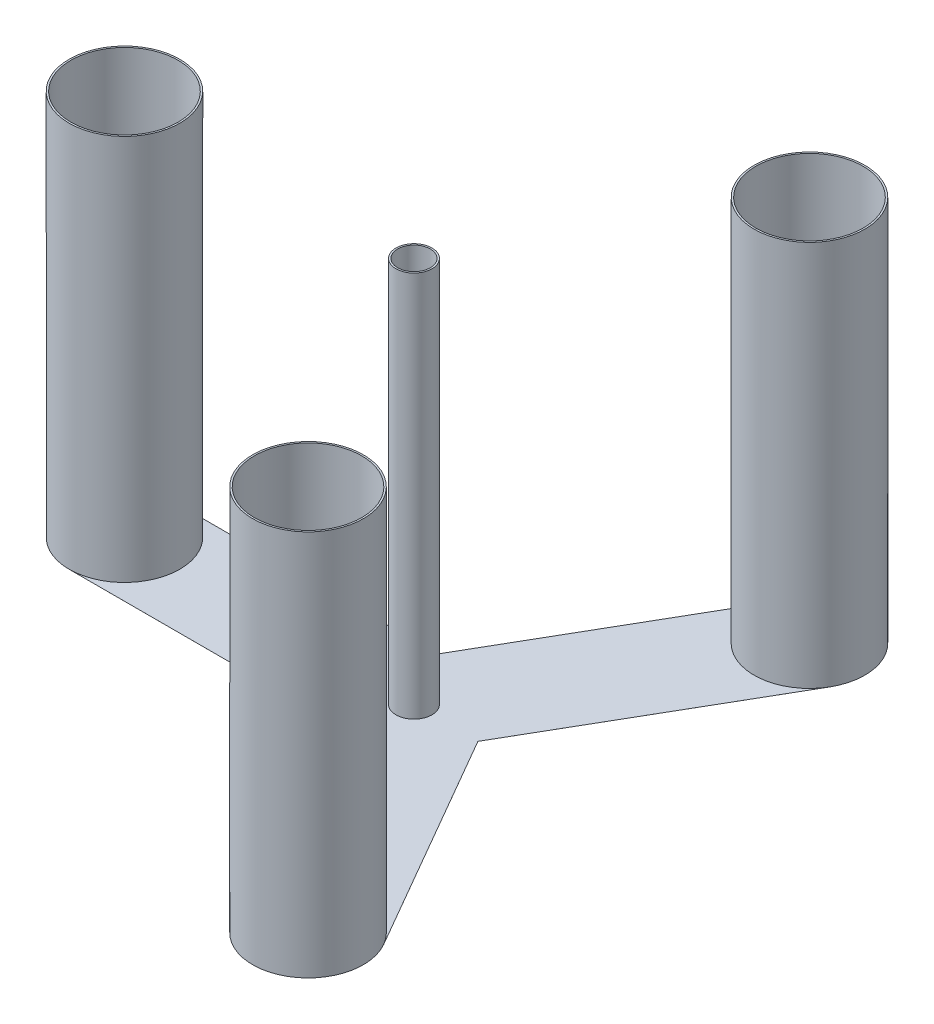
from build123d import *

# Parameters (mm, degrees)
BOSS_EXTRUDE1_DEPTH = 0.01
SKETCH2_R           = 64.5
SKETCH2_R_2         = 62.5
SKETCH2_R_3         = 21
SKETCH2_R_4         = 19
BOSS_EXTRUDE2_DEPTH = 450


with BuildPart() as part:
    # Sketch1 → Boss-Extrude1 (new body)
    with BuildSketch(Plane(origin=(0, 0, 0), x_dir=(1, 0, 0), z_dir=(0, 1, 0))):
        with BuildLine():
            Line((-37.239092363, 64.5), (-337.239092363, 64.5))
            ThreePointArc((-337.239092363, 64.5), (-401.739092363, 0), (-337.239092363, -64.5))
            Line((-337.239092363, -64.5), (-37.239092363, -64.5))
            Line((-37.239092363, -64.5), (112.760907637, -324.307621135))
            ThreePointArc((112.760907637, -324.307621135), (200.869546181, -347.916259679), (224.478184725, -259.807621135))
            Line((224.478184725, -259.807621135), (74.478184725, 0))
            Line((74.478184725, 0), (224.478184725, 259.807621135))
            ThreePointArc((224.478184725, 259.807621135), (200.869546181, 347.916259679), (112.760907637, 324.307621135))
            Line((112.760907637, 324.307621135), (-37.239092363, 64.5))
        make_face()
    extrude(amount=BOSS_EXTRUDE1_DEPTH)

    # Sketch2 → Boss-Extrude2 (add)
    with BuildSketch(Plane(origin=(0, 0.01, 0), x_dir=(1, 0, 0), z_dir=(0, 1, 0))):
        with Locations((168.619546181, 292.057621135)):
            Circle(SKETCH2_R)
        with Locations((168.619546181, 292.057621135)):
            Circle(SKETCH2_R_2, mode=Mode.SUBTRACT)
        with Locations((-337.239092363, 0)):
            Circle(SKETCH2_R)
        with Locations((-337.239092363, 0)):
            Circle(SKETCH2_R_2, mode=Mode.SUBTRACT)
        with Locations((168.619546181, -292.057621135)):
            Circle(SKETCH2_R)
        with Locations((168.619546181, -292.057621135)):
            Circle(SKETCH2_R_2, mode=Mode.SUBTRACT)
        Circle(SKETCH2_R_3)
        Circle(SKETCH2_R_4, mode=Mode.SUBTRACT)
    extrude(amount=BOSS_EXTRUDE2_DEPTH)


solid = part.part
